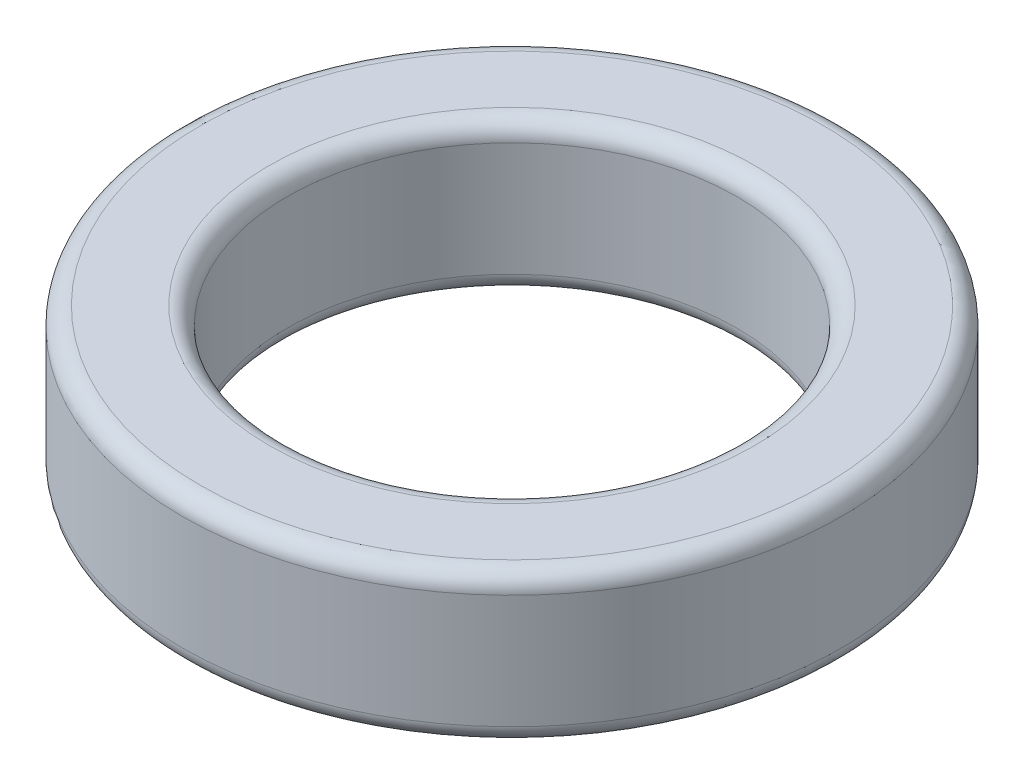
from build123d import *

# Parameters (mm, degrees)
SKETCH_1_W = 1.75
SKETCH_1_H = 2.5
FILLET_1_R = 0.3


with BuildPart() as part:
    # Эскиз1 → Повернуть1 (revolve)
    with BuildSketch(Plane.XY):
        with Locations((4.625, 1.25)):
            Rectangle(SKETCH_1_W, SKETCH_1_H)
    revolve(axis=Axis((0, 0, 0), (0, 1, 0)))

    # Скругление1
    fillet_1_edges = [part.edges().sort_by_distance(p)[0] for p in [
        (-5.5, 0, 0),
        (-5.5, 2.5, 0),
        (-3.75, 2.5, 0),
        (-3.75, 0, 0),
    ]]
    fillet(fillet_1_edges, radius=FILLET_1_R)


solid = part.part
